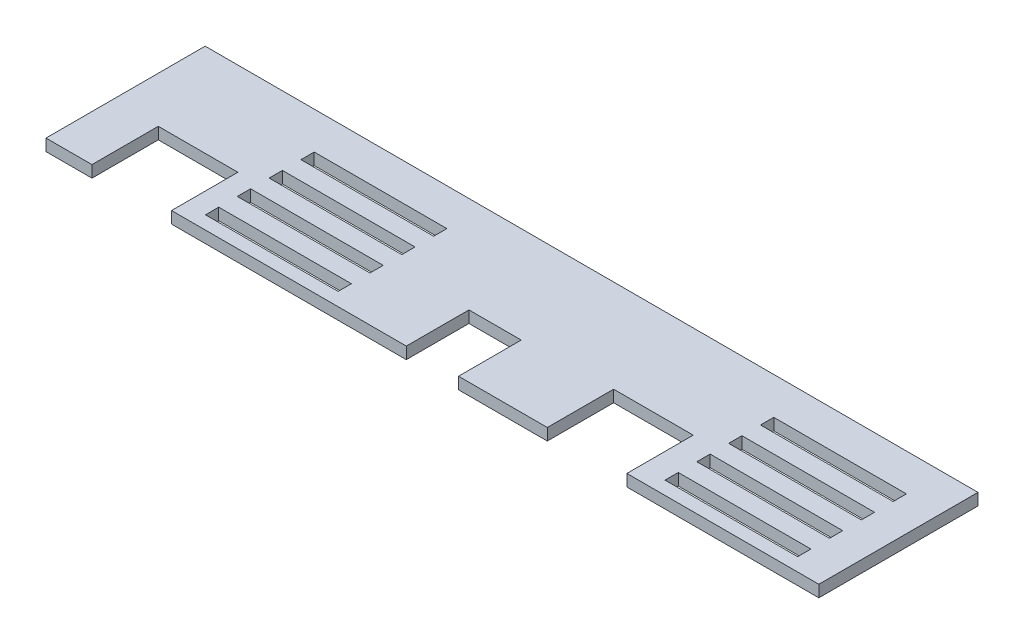
from build123d import *

# Parameters (mm, degrees)
BOSS_EXTRUDE1_DEPTH  = 5.6388
SKETCH2_W            = 63.5
SKETCH2_H            = 6.35
CUT_EXTRUDE1_DEPTH   = 6.6388
LPATTERN1_COUNT      = 4
LPATTERN1_PITCH      = 15.24
LPATTERN1_COUNT_DIR2 = 2
LPATTERN1_PITCH_DIR2 = 220
SKETCH3_W            = 25
SKETCH3_H            = 30
CUT_EXTRUDE2_DEPTH   = 6.6388
SKETCH4_W            = 38.1
SKETCH4_H            = 31.75
CUT_EXTRUDE3_DEPTH   = 6.6388


with BuildPart() as part:
    # Sketch1 → Boss-Extrude1 (new body)
    with BuildSketch(Plane(origin=(0, 0, 0), x_dir=(1, 0, 0), z_dir=(0, 1, 0))):
        Polygon((-185, -73.025), (185, -73.025), (185, -6.825), (185, 3.175), (175, 3.175), (-175, 3.175), (-185, 3.175), (-185, -6.825), align=None)
    extrude(amount=BOSS_EXTRUDE1_DEPTH)

    # Sketch2 → Cut-Extrude1 (cut, through all)
    with BuildSketch(Plane(origin=(0, 5.6388, 0), x_dir=(1, 0, 0), z_dir=(0, 1, 0))):
        with Locations((-83.25, -63.5)):
            Rectangle(SKETCH2_W, SKETCH2_H)
    cut_extrude1 = extrude(amount=-CUT_EXTRUDE1_DEPTH, mode=Mode.SUBTRACT)

    # LPattern1: Cut-Extrude1 4 × 2
    with Locations(*[(j * LPATTERN1_PITCH_DIR2, 0, -i * LPATTERN1_PITCH) for i in range(LPATTERN1_COUNT) for j in range(LPATTERN1_COUNT_DIR2) if (i, j) != (0, 0)]):
        add(cut_extrude1, mode=Mode.SUBTRACT)

    # Sketch3 → Cut-Extrude2 (cut, through all)
    with BuildSketch(Plane(origin=(0, 5.6388, 0), x_dir=(1, 0, 0), z_dir=(0, 1, 0))):
        with Locations((0, -58.025)):
            Rectangle(SKETCH3_W, SKETCH3_H)
    extrude(amount=-CUT_EXTRUDE2_DEPTH, mode=Mode.SUBTRACT)

    # Sketch4 → Cut-Extrude3 (cut, through all)
    with BuildSketch(Plane(origin=(0, 5.6388, 0), x_dir=(1, 0, 0), z_dir=(0, 1, 0))):
        with Locations((-143.95, -57.15)):
            Rectangle(SKETCH4_W, SKETCH4_H)
        with Locations((74.05, -57.15)):
            Rectangle(SKETCH4_W, SKETCH4_H)
    extrude(amount=-CUT_EXTRUDE3_DEPTH, mode=Mode.SUBTRACT)


solid = part.part
